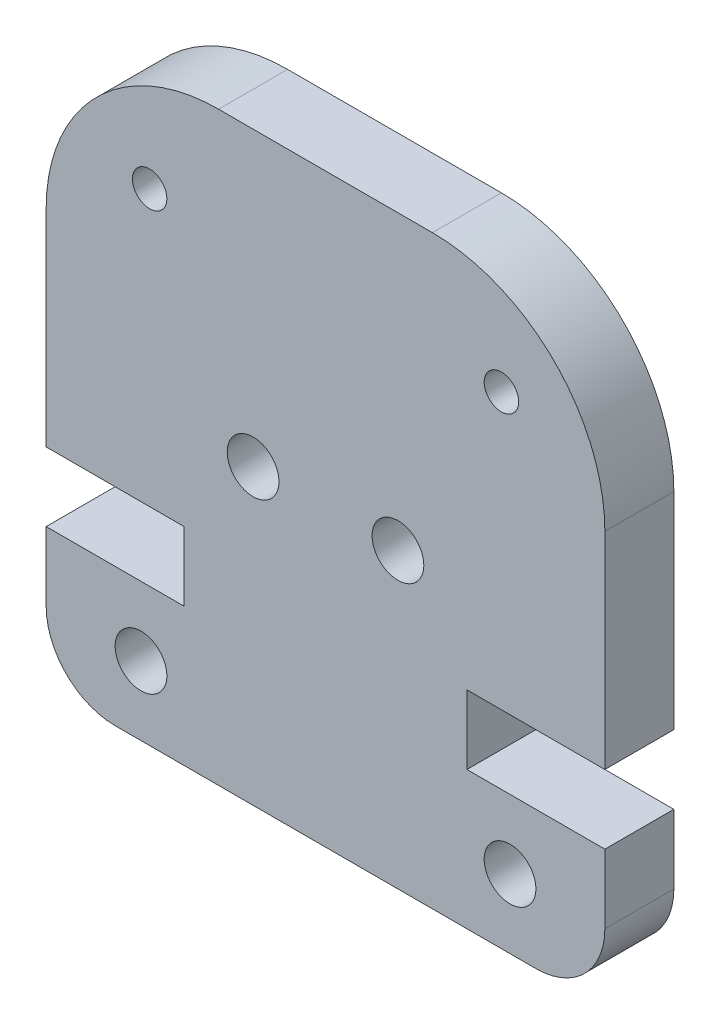
from build123d import *

# Parameters (mm, degrees)
SKETCH1_R           = 0.75
SKETCH1_R_2         = 0.5
BOSS_EXTRUDE1_DEPTH = 2


with BuildPart() as part:
    # Sketch1 → Boss-Extrude1 (new body)
    with BuildSketch(Plane.XY):
        with BuildLine():
            Line((3.1, 16.98), (-3.1, 16.98))
            ThreePointArc((-3.1, 16.98), (-6.635533906, 15.515533906), (-8.1, 11.98))
            Line((-8.1, 11.98), (-8.1, 6))
            Line((-8.1, 6), (-4.1, 6))
            Line((-4.1, 6), (-4.1, 4))
            Line((-4.1, 4), (-8.1, 4))
            Line((-8.1, 4), (-8.1, 2))
            ThreePointArc((-8.1, 2), (-7.514213562, 0.585786438), (-6.1, 0))
            Line((-6.1, 0), (6.1, 0))
            ThreePointArc((6.1, 0), (7.514213562, 0.585786438), (8.1, 2))
            Line((8.1, 2), (8.1, 4))
            Line((8.1, 4), (4.1, 4))
            Line((4.1, 4), (4.1, 6))
            Line((4.1, 6), (8.1, 6))
            Line((8.1, 6), (8.1, 11.98))
            ThreePointArc((8.1, 11.98), (6.635533906, 15.515533906), (3.1, 16.98))
        make_face()
        with Locations((-5.35, 2)):
            Circle(SKETCH1_R, mode=Mode.SUBTRACT)
        with Locations((-5.1, 13.98)):
            Circle(SKETCH1_R_2, mode=Mode.SUBTRACT)
        with Locations((-2.1, 8.5)):
            Circle(SKETCH1_R, mode=Mode.SUBTRACT)
        with Locations((2.1, 8.5)):
            Circle(SKETCH1_R, mode=Mode.SUBTRACT)
        with Locations((5.1, 13.98)):
            Circle(SKETCH1_R_2, mode=Mode.SUBTRACT)
        with Locations((5.35, 2)):
            Circle(SKETCH1_R, mode=Mode.SUBTRACT)
    extrude(amount=BOSS_EXTRUDE1_DEPTH)


solid = part.part
